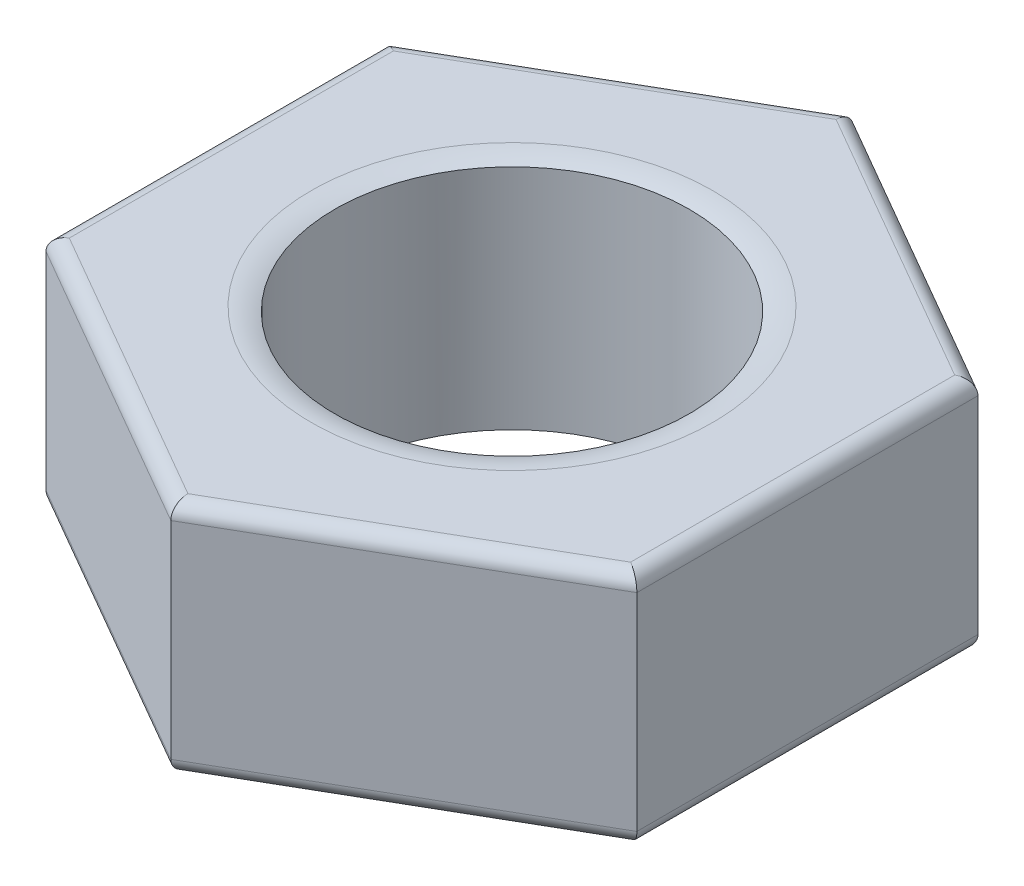
from build123d import *

# Parameters (mm, degrees)
SKETCH1_R           = 1.5
BOSS_EXTRUDE1_DEPTH = 2
FILLET1_R           = 0.125


with BuildPart() as part:
    # Sketch1 → Boss-Extrude1 (new body)
    with BuildSketch(Plane(origin=(0, 0, 0), x_dir=(1, 0, 0), z_dir=(0, 1, 0))):
        Polygon((0, 2.886751346), (-2.5, 1.443375673), (-2.5, -1.443375673), (0, -2.886751346), (2.5, -1.443375673), (2.5, 1.443375673), align=None)
        Circle(SKETCH1_R, mode=Mode.SUBTRACT)
    extrude(amount=BOSS_EXTRUDE1_DEPTH)

    # Fillet1
    fillet1_edges = [part.edges().sort_by_distance(p)[0] for p in [
        (-2.5, 2, 0),
        (-1.25, 2, 2.165063509),
        (1.25, 2, 2.165063509),
        (2.5, 2, 0),
        (1.25, 2, -2.165063509),
        (2.5, 0, 0),
        (1.25, 0, 2.165063509),
        (-1.25, 0, 2.165063509),
        (-1.25, 2, -2.165063509),
        (-2.5, 0, 0),
        (-1.25, 0, -2.165063509),
        (1.25, 0, -2.165063509),
    ]]
    fillet(fillet1_edges, radius=FILLET1_R)

    # Sketch5 → Cut-Revolve1 (revolve, cut)
    with BuildSketch(Plane(origin=(0, 0, 0), x_dir=(0, 0, -1), z_dir=(1, 0, 0))):
        with BuildLine():
            Line((1.699485543, 2), (1.761177848, 2))
            Line((1.761177848, 2), (1.761177848, 2.100760071))
            Line((1.761177848, 2.100760071), (1.194006659, 2.100760071))
            Line((1.194006659, 2.100760071), (1.194006659, 1.686410093))
            ThreePointArc((1.194006659, 1.686410093), (1.402060119, 1.915234853), (1.699485543, 2))
        make_face()
        with BuildLine():
            Line((1.194006659, -0.100760071), (1.194006659, 0.313589907))
            ThreePointArc((1.194006659, 0.313589907), (1.402060119, 0.084765147), (1.699485543, 0))
            Line((1.699485543, 0), (1.761177848, 0))
            Line((1.761177848, 0), (1.761177848, -0.100760071))
            Line((1.761177848, -0.100760071), (1.194006659, -0.100760071))
        make_face()
    revolve(axis=Axis((0, 0, 0), (0, 1, 0)), mode=Mode.SUBTRACT)


solid = part.part
